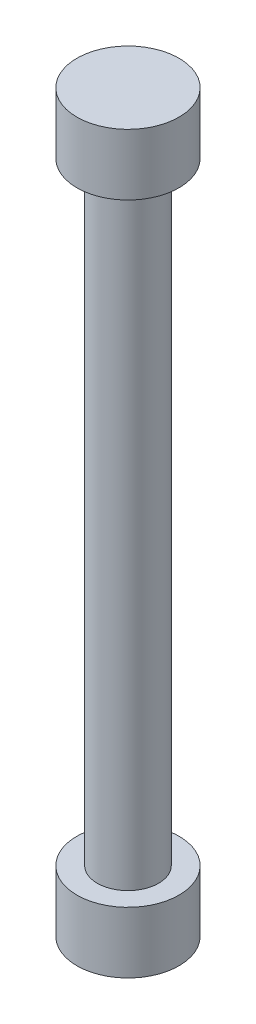
from build123d import *

# Parameters (mm, degrees)
SKETCH1_R           = 0.9525
BOSS_EXTRUDE1_DEPTH = 9.525
SKETCH2_R           = 1.5875
BOSS_EXTRUDE2_DEPTH = 1.905


with BuildPart() as part:
    # Sketch1 → Boss-Extrude1 (new body)
    with BuildSketch(Plane(origin=(0, 0, 0), x_dir=(1, 0, 0), z_dir=(0, 1, 0))):
        Circle(SKETCH1_R)
    boss_extrude1 = extrude(amount=BOSS_EXTRUDE1_DEPTH)

    # Sketch2 → Boss-Extrude2 (add)
    with BuildSketch(Plane(origin=(0, 9.525, 0), x_dir=(1, 0, 0), z_dir=(0, 1, 0))):
        Circle(SKETCH2_R)
    boss_extrude2 = extrude(amount=BOSS_EXTRUDE2_DEPTH)

    # Mirror1: Boss-Extrude1, Boss-Extrude2 across plane
    add(boss_extrude1.mirror(Plane.ZX))
    add(boss_extrude2.mirror(Plane.ZX))


solid = part.part
